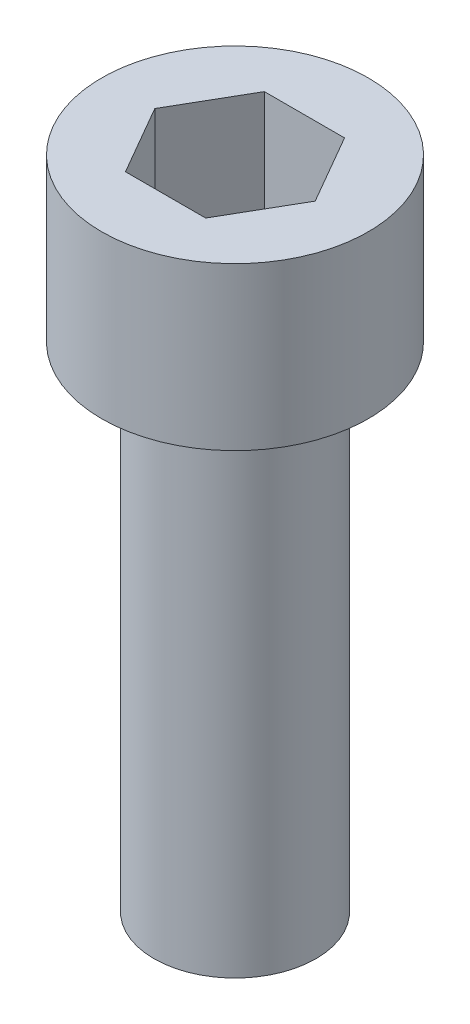
from build123d import *

# Parameters (mm, degrees)
CUT_EXTRUDE1_DEPTH = 3.571875


with BuildPart() as part:
    # profiile → Base-Revolve (revolve)
    with BuildSketch(Plane.XY):
        Polygon((0, 4.1656), (3.429, 4.1656), (3.429, 0), (2.0828, 0), (2.0828, -12.7), (0, -12.7), align=None)
    revolve(axis=Axis((0, 9.907210965, 0), (0, -1, 0)))

    # Sketch1 → Cut-Extrude1 (cut)
    with BuildSketch(Plane(origin=(0, 4.1656, 0), x_dir=(1, 0, 0), z_dir=(0, 1, 0))):
        Polygon((2.062222993, 0), (1.031111496, 1.7859375), (-1.031111496, 1.7859375), (-2.062222993, 0), (-1.031111496, -1.7859375), (1.031111496, -1.7859375), align=None)
    extrude(amount=-CUT_EXTRUDE1_DEPTH, mode=Mode.SUBTRACT)


solid = part.part
